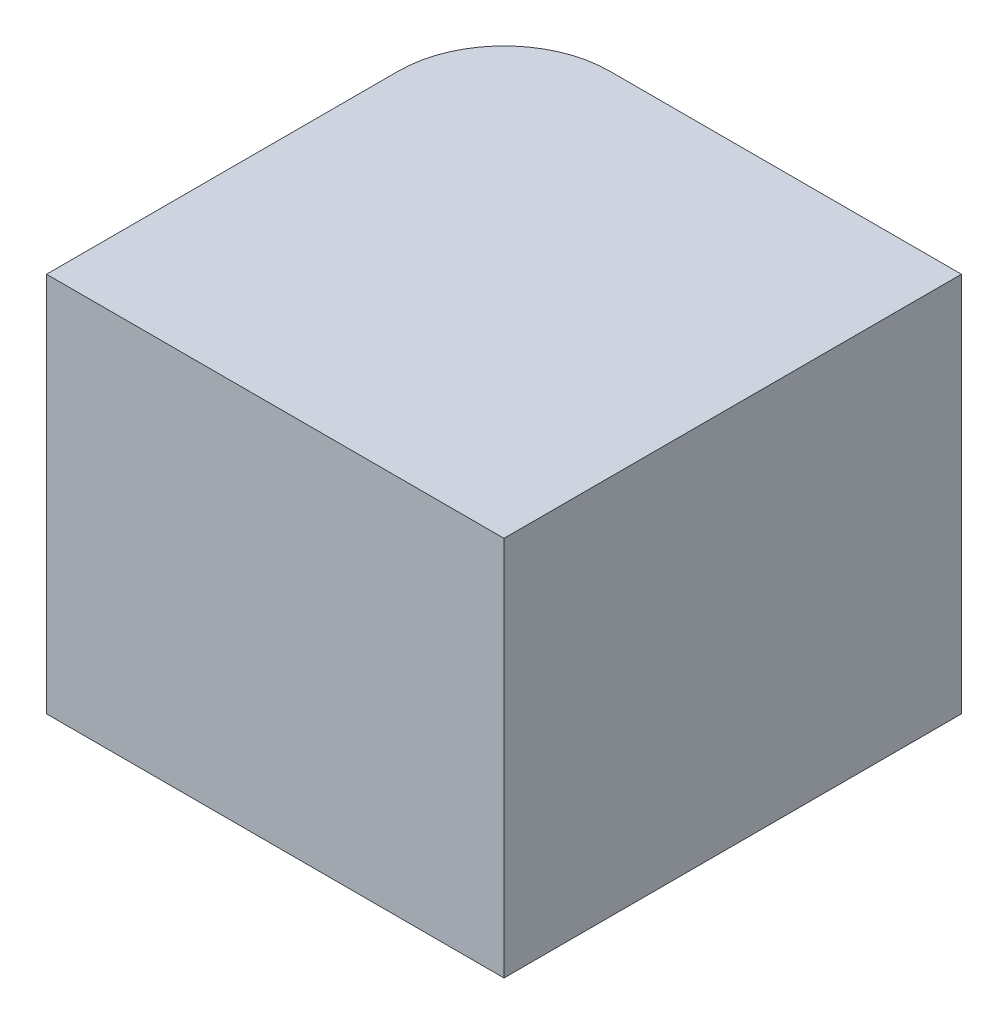
from build123d import *

# Parameters (mm, degrees)
SKETCH2_W           = 8.65
SKETCH2_H           = 8.65
BOSS_EXTRUDE1_DEPTH = 7.2
FILLET1_R           = 2


with BuildPart() as part:
    # Sketch2 → Boss-Extrude1 (new body)
    with BuildSketch(Plane(origin=(0, 0, 0), x_dir=(1, 0, 0), z_dir=(0, 1, 0))):
        with Locations((4.325, 4.325)):
            Rectangle(SKETCH2_W, SKETCH2_H)
    extrude(amount=BOSS_EXTRUDE1_DEPTH)

    # Fillet1
    fillet1_edges = [part.edges().sort_by_distance(p)[0] for p in [
        (0, 3.6, -8.65),
    ]]
    fillet(fillet1_edges, radius=FILLET1_R)


solid = part.part
